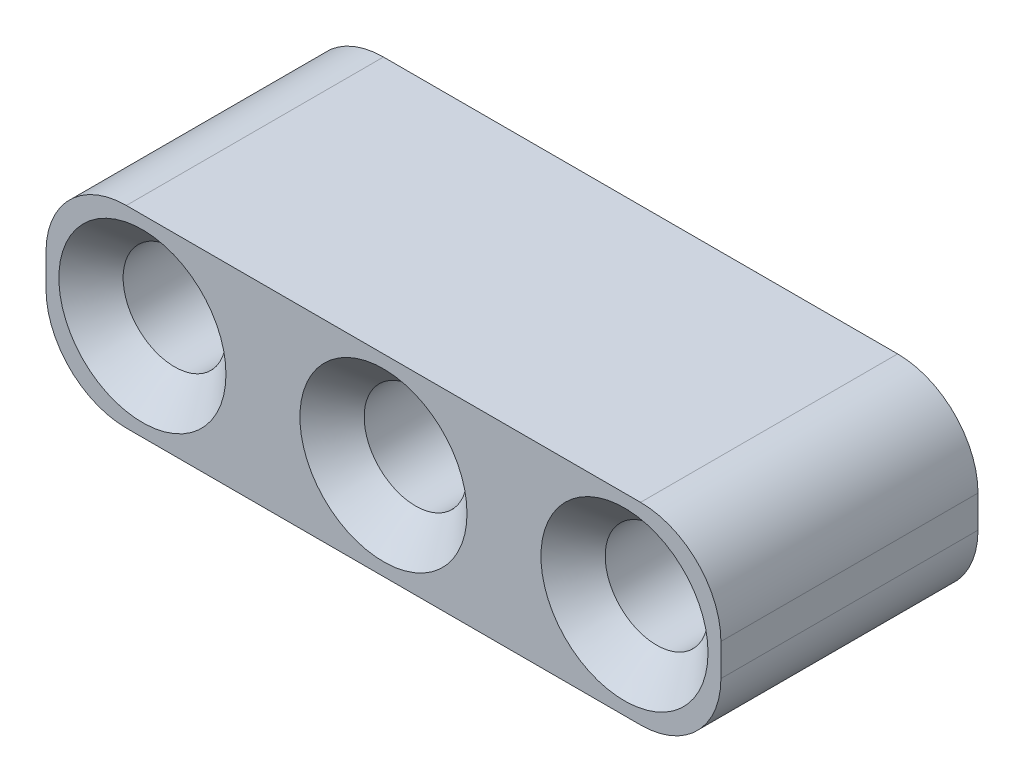
from build123d import *

# Parameters (mm, degrees)
SKETCH1_R           = 1.6
BOSS_EXTRUDE1_DEPTH = 8
CHAMFER1_SIZE       = 1


with BuildPart() as part:
    # Sketch1 → Boss-Extrude1 (new body)
    with BuildSketch(Plane.XY):
        with BuildLine():
            Line((-0.5, 3), (15.5, 3))
            ThreePointArc((15.5, 3), (17.267766953, 2.267766953), (18, 0.5))
            Line((18, 0.5), (18, -0.5))
            ThreePointArc((18, -0.5), (17.267766953, -2.267766953), (15.5, -3))
            Line((15.5, -3), (-0.5, -3))
            ThreePointArc((-0.5, -3), (-2.267766953, -2.267766953), (-3, -0.5))
            Line((-3, -0.5), (-3, 0.5))
            ThreePointArc((-3, 0.5), (-2.267766953, 2.267766953), (-0.5, 3))
        make_face()
        Circle(SKETCH1_R, mode=Mode.SUBTRACT)
        with Locations((7.5, 0)):
            Circle(SKETCH1_R, mode=Mode.SUBTRACT)
        with Locations((15, 0)):
            Circle(SKETCH1_R, mode=Mode.SUBTRACT)
    extrude(amount=BOSS_EXTRUDE1_DEPTH)

    # Chamfer1
    chamfer1_edges = [part.edges().sort_by_distance(p)[0] for p in [
        (-1.6, 0, 0),
        (-1.6, 0, 8),
        (5.9, 0, 0),
        (5.9, 0, 8),
        (13.4, 0, 0),
        (13.4, 0, 8),
    ]]
    chamfer(chamfer1_edges, length=CHAMFER1_SIZE)


solid = part.part
